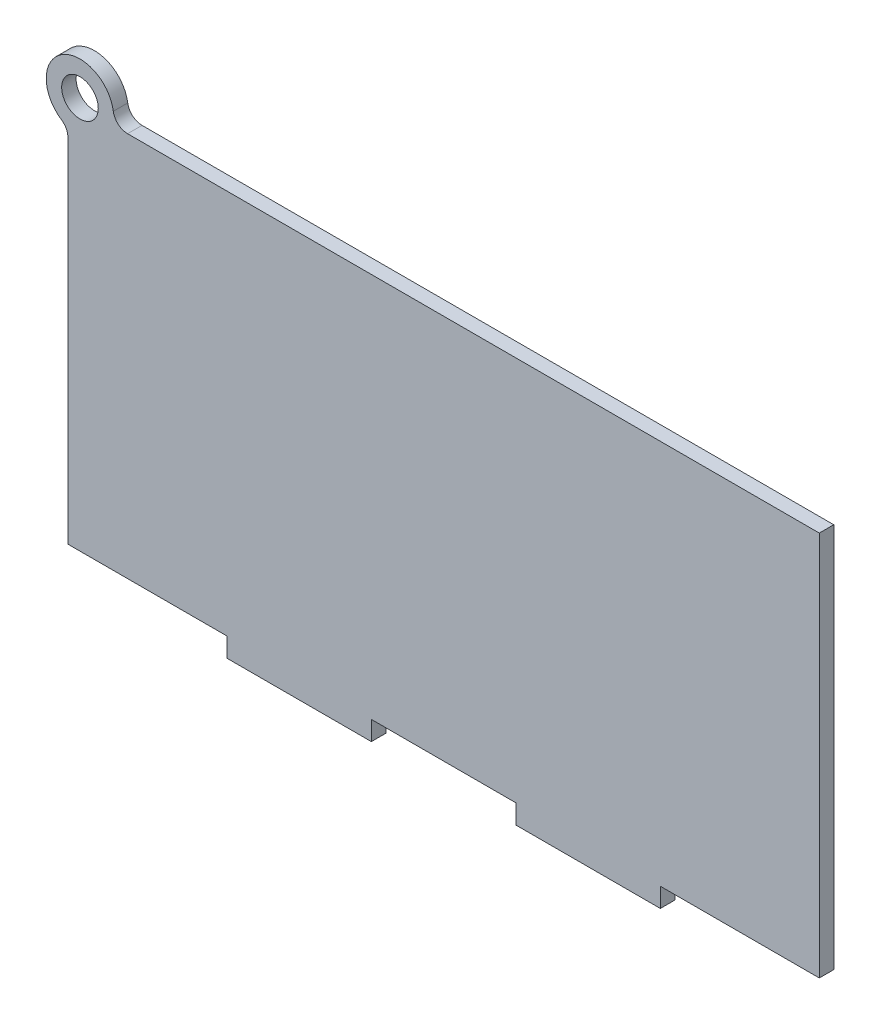
from build123d import *

# Parameters (mm, degrees)
SKETCH1_R           = 3.8
BOSS_EXTRUDE1_DEPTH = 3


with BuildPart() as part:
    # Sketch1 → Boss-Extrude1 (new body)
    with BuildSketch(Plane.XY):
        with BuildLine():
            Line((-45.446220454, -41.816247618), (-45.446220454, -37.816247618))
            Line((-45.446220454, -37.816247618), (-75.446220454, -37.816247618))
            Line((-75.446220454, -37.816247618), (-78.446220454, -37.816247618))
            Line((-78.446220454, -37.816247618), (-78.446220454, 35.332105838))
            ThreePointArc((-78.446220454, 35.332105838), (-78.805197925, 36.755130785), (-79.796220454, 37.837599801))
            ThreePointArc((-79.796220454, 37.837599801), (-79.720698736, 49.578946501), (-69.025418478, 44.733752382))
            ThreePointArc((-69.025418478, 44.733752382), (-68.015121209, 42.908889749), (-66.059360488, 42.183752382))
            Line((-66.059360488, 42.183752382), (77.553779546, 42.183752382))
            Line((77.553779546, 42.183752382), (77.553779546, -37.816247618))
            Line((77.553779546, -37.816247618), (44.553779546, -37.816247618))
            Line((44.553779546, -37.816247618), (44.553779546, -41.816247618))
            Line((44.553779546, -41.816247618), (14.553779546, -41.816247618))
            Line((14.553779546, -41.816247618), (14.553779546, -37.816247618))
            Line((14.553779546, -37.816247618), (-15.446220454, -37.816247618))
            Line((-15.446220454, -37.816247618), (-15.446220454, -41.816247618))
            Line((-15.446220454, -41.816247618), (-45.446220454, -41.816247618))
        make_face()
        with Locations((-75.946220454, 43.683752382)):
            Circle(SKETCH1_R, mode=Mode.SUBTRACT)
    extrude(amount=BOSS_EXTRUDE1_DEPTH)


solid = part.part
